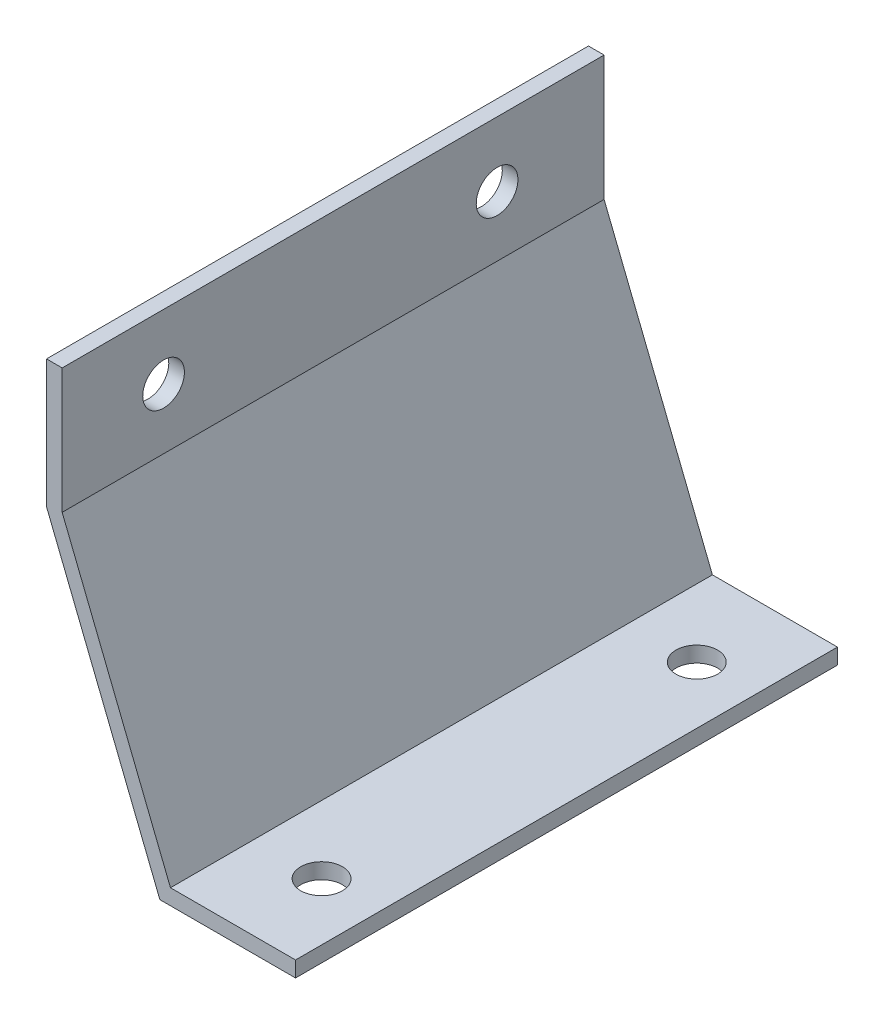
from build123d import *

# Parameters (mm, degrees)
EXTRUDE_THIN1_DEPTH = 165.1
SKETCH2_R           = 6.35
CUT_EXTRUDE1_DEPTH  = 5.7625
SKETCH3_R           = 6.35
CUT_EXTRUDE2_DEPTH  = 5.7625


with BuildPart() as part:
    # Sketch1 → Extrude-Thin1 (new body)
    with BuildSketch(Plane.XY):
        Polygon((0, 120.65), (0, 82.55), (32.995567884, 0), (71.095567884, 0), (71.095567884, -4.7625), (29.770312185, -4.7625), (-4.7625, 81.633456448), (-4.7625, 120.65), align=None)
    extrude(amount=EXTRUDE_THIN1_DEPTH)

    # Sketch2 → Cut-Extrude1 (cut, through all)
    with BuildSketch(Plane(origin=(0, 0, 0), x_dir=(0, 0, -1), z_dir=(1, 0, 0))):
        with Locations((-134.204880657, 100.94227704)):
            Circle(SKETCH2_R)
        with Locations((-32.604880657, 100.94227704)):
            Circle(SKETCH2_R)
    extrude(amount=-CUT_EXTRUDE1_DEPTH, mode=Mode.SUBTRACT)

    # Sketch3 → Cut-Extrude2 (cut, through all)
    with BuildSketch(Plane(origin=(0, 0, 0), x_dir=(1, 0, 0), z_dir=(0, 1, 0))):
        with Locations((53.633067884, -25.4)):
            Circle(SKETCH3_R)
        with Locations((53.633067884, -139.7)):
            Circle(SKETCH3_R)
    extrude(amount=-CUT_EXTRUDE2_DEPTH, mode=Mode.SUBTRACT)


solid = part.part
